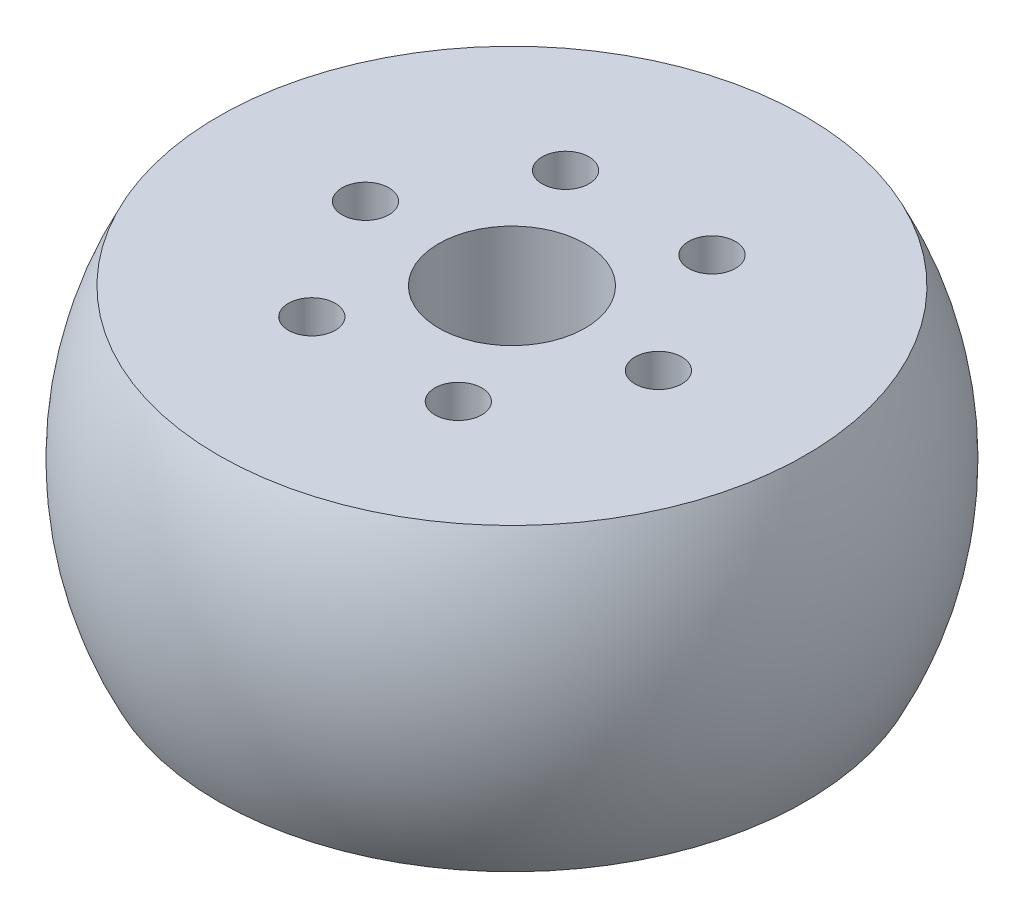
from build123d import *

# Parameters (mm, degrees)
SKETCH3_R          = 1.016
CUT_EXTRUDE1_DEPTH = 7.5
CIRPATTERN1_COUNT  = 6


with BuildPart() as part:
    # Sketch1 → Revolve1 (revolve)
    with BuildSketch(Plane(origin=(0, 0, 0), x_dir=(0, 0, -1), z_dir=(1, 0, 0))):
        with BuildLine():
            Line((3.175, 6.5), (12.723311528, 6.5))
            ThreePointArc((12.723311528, 6.5), (14.2875, 0), (12.723311528, -6.5))
            Line((12.723311528, -6.5), (3.175, -6.5))
            Line((3.175, -6.5), (3.175, 6.5))
        make_face()
    revolve(axis=Axis((0, -6.5, 0), (0, 1, 0)))

    # Sketch3 → Cut-Extrude1 (cut, symmetric)
    with BuildSketch(Plane(origin=(0, 0, 0), x_dir=(1, 0, 0), z_dir=(0, 1, 0))):
        with Locations((6.35, 0)):
            Circle(SKETCH3_R)
    cut_extrude1 = extrude(amount=CUT_EXTRUDE1_DEPTH, both=True, mode=Mode.SUBTRACT)

    # CirPattern1: Cut-Extrude1 ×6 about axis
    cirpattern1_axis = Axis((0, 0, 0), (0, 1, 0))
    for i in range(1, CIRPATTERN1_COUNT):
        add(cut_extrude1.rotate(cirpattern1_axis, i * 360 / CIRPATTERN1_COUNT), mode=Mode.SUBTRACT)


solid = part.part
